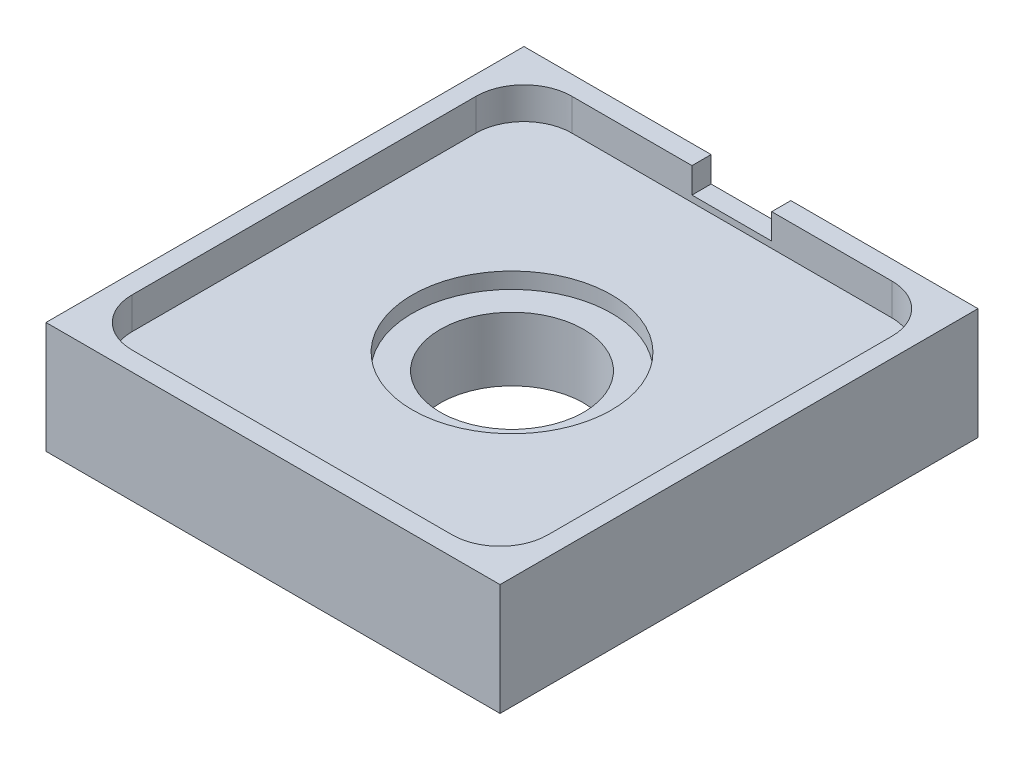
from build123d import *

# Parameters (mm, degrees)
SKETCH1_W           = 28.47
SKETCH1_H           = 29.97
BOSS_EXTRUDE1_DEPTH = 5
CUT_EXTRUDE1_REACH  = 7
SKETCH2_R           = 4.5
SKETCH4_W           = 28.47
SKETCH4_H           = 29.97
SKETCH4_W_2         = 26.07
SKETCH4_H_2         = 27.57
BOSS_EXTRUDE2_DEPTH = 2
SKETCH7_R           = 6.25
CUT_EXTRUDE5_DEPTH  = 1
FILLET1_R           = 3
SKETCH8_W           = 5
SKETCH8_H           = 1.6
CUT_EXTRUDE6_DEPTH  = 1.2


with BuildPart() as part:
    # Sketch1 → Boss-Extrude1 (new body)
    with BuildSketch(Plane(origin=(0, 0, 0), x_dir=(1, 0, 0), z_dir=(0, 1, 0))):
        Rectangle(SKETCH1_W, SKETCH1_H)
    extrude(amount=-BOSS_EXTRUDE1_DEPTH)

    # Sketch2 → Cut-Extrude1 (cut, up to next)
    with BuildSketch(Plane(origin=(0, 0, 0), x_dir=(1, 0, 0), z_dir=(0, 1, 0)), mode=Mode.PRIVATE) as cut_extrude1_sk1:
        Circle(SKETCH2_R)
    cut_extrude1_tool1 = extrude(cut_extrude1_sk1.sketch, amount=-CUT_EXTRUDE1_REACH, mode=Mode.PRIVATE) & part.part
    add(cut_extrude1_tool1.solids().sort_by_distance((0, 0, 0))[0], mode=Mode.SUBTRACT)

    # Sketch4 → Boss-Extrude2 (add)
    with BuildSketch(Plane(origin=(0, 0, 0), x_dir=(1, 0, 0), z_dir=(0, 1, 0))):
        Rectangle(SKETCH4_W, SKETCH4_H)
        Rectangle(SKETCH4_W_2, SKETCH4_H_2, mode=Mode.SUBTRACT)
    extrude(amount=BOSS_EXTRUDE2_DEPTH)

    # Sketch7 → Cut-Extrude5 (cut)
    with BuildSketch(Plane(origin=(0, 0, 0), x_dir=(1, 0, 0), z_dir=(0, 1, 0))):
        Circle(SKETCH7_R)
    extrude(amount=-CUT_EXTRUDE5_DEPTH, mode=Mode.SUBTRACT)

    # Fillet1
    fillet1_edges = [part.edges().sort_by_distance(p)[0] for p in [
        (13.035, 1, -13.785),
        (-13.035, 1, -13.785),
        (-13.035, 1, 13.785),
        (13.035, 1, 13.785),
    ]]
    fillet(fillet1_edges, radius=FILLET1_R)

    # Sketch8 → Cut-Extrude6 (cut)
    with BuildSketch(Plane(origin=(0, 0, -14.985), x_dir=(-1, 0, 0), z_dir=(0, 0, -1))):
        with Locations((0, 1.2)):
            Rectangle(SKETCH8_W, SKETCH8_H)
    extrude(amount=-CUT_EXTRUDE6_DEPTH, mode=Mode.SUBTRACT)


solid = part.part
